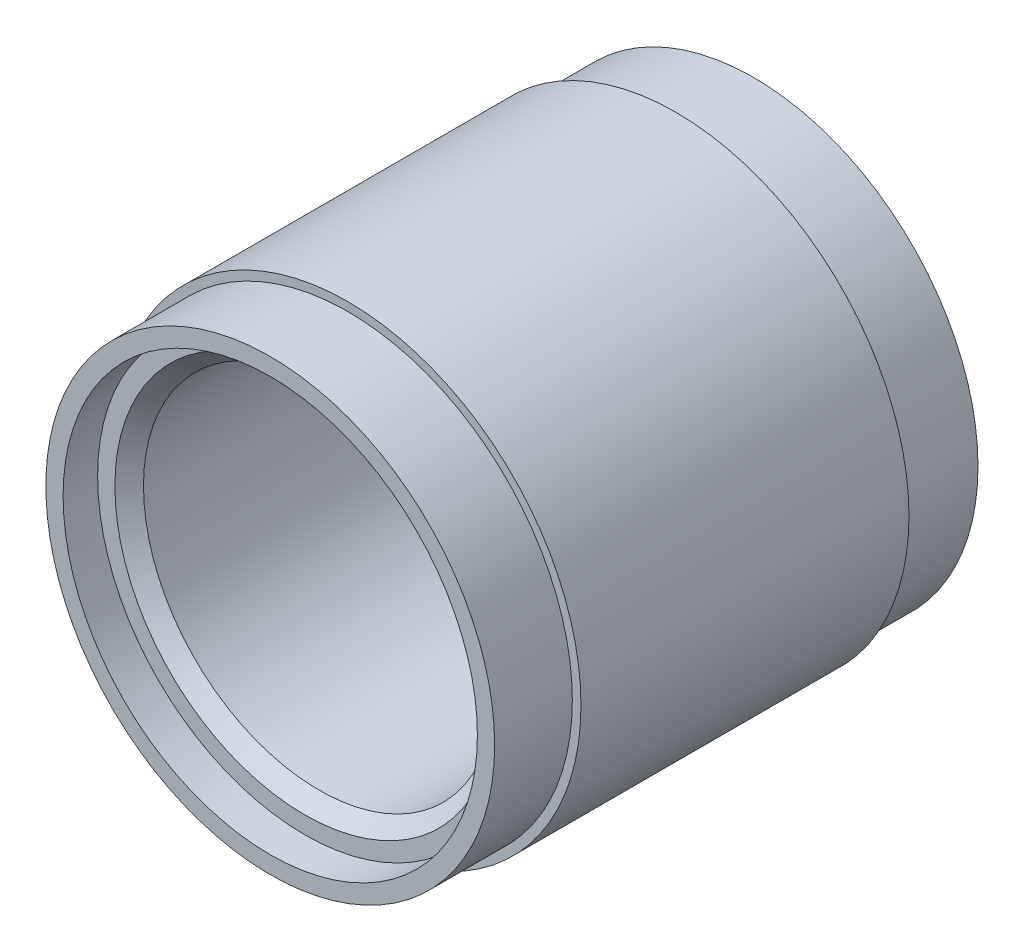
from build123d import *

# Parameters (mm, degrees)
SKETCH_2_R          = 13
EXTRUDE_1_DEPTH     = 4.5
SKETCH_3_R          = 13.5
EXTRUDE_2_DEPTH     = 9.5
SKETCH_4_R          = 12
CUT_EXTRUDE_1_DEPTH = 2
SKETCH_5_R          = 10.172
CUT_EXTRUDE_2_DEPTH = 27
CHAMFER_1_SIZE      = 0.828


with BuildPart() as part:
    # Эскиз2 → Бобышка-Вытянуть1 (new body)
    with BuildSketch(Plane.XY):
        Circle(SKETCH_2_R)
    extrude(amount=EXTRUDE_1_DEPTH)

    # Эскиз3 → Бобышка-Вытянуть2 (add)
    with BuildSketch(Plane.XY.offset(4.5)):
        Circle(SKETCH_3_R)
    extrude(amount=EXTRUDE_2_DEPTH)

    # Эскиз4 → Вырез-Вытянуть1 (cut)
    with BuildSketch(Plane(origin=(0, 0, 0), x_dir=(-1, 0, 0), z_dir=(0, 0, -1))):
        Circle(SKETCH_4_R)
    extrude(amount=-CUT_EXTRUDE_1_DEPTH, mode=Mode.SUBTRACT)

    # Зеркальное отражение4: part across plane


with BuildPart() as part_1:
    add(part.part)
    add(part.part.mirror(Plane.XY.offset(14)))

    # Эскиз5 → Вырез-Вытянуть2 (cut, through all)
    with BuildSketch(Plane(origin=(0, 0, 2), x_dir=(-1, 0, 0), z_dir=(0, 0, -1))):
        Circle(SKETCH_5_R)
    extrude(amount=-CUT_EXTRUDE_2_DEPTH, mode=Mode.SUBTRACT)

    # Фаска1
    chamfer_1_edges = [part_1.edges().sort_by_distance(p)[0] for p in [
        (10.172, 0, 26),
        (10.172, 0, 2),
    ]]
    chamfer(chamfer_1_edges, length=CHAMFER_1_SIZE)


solid = part_1.part
